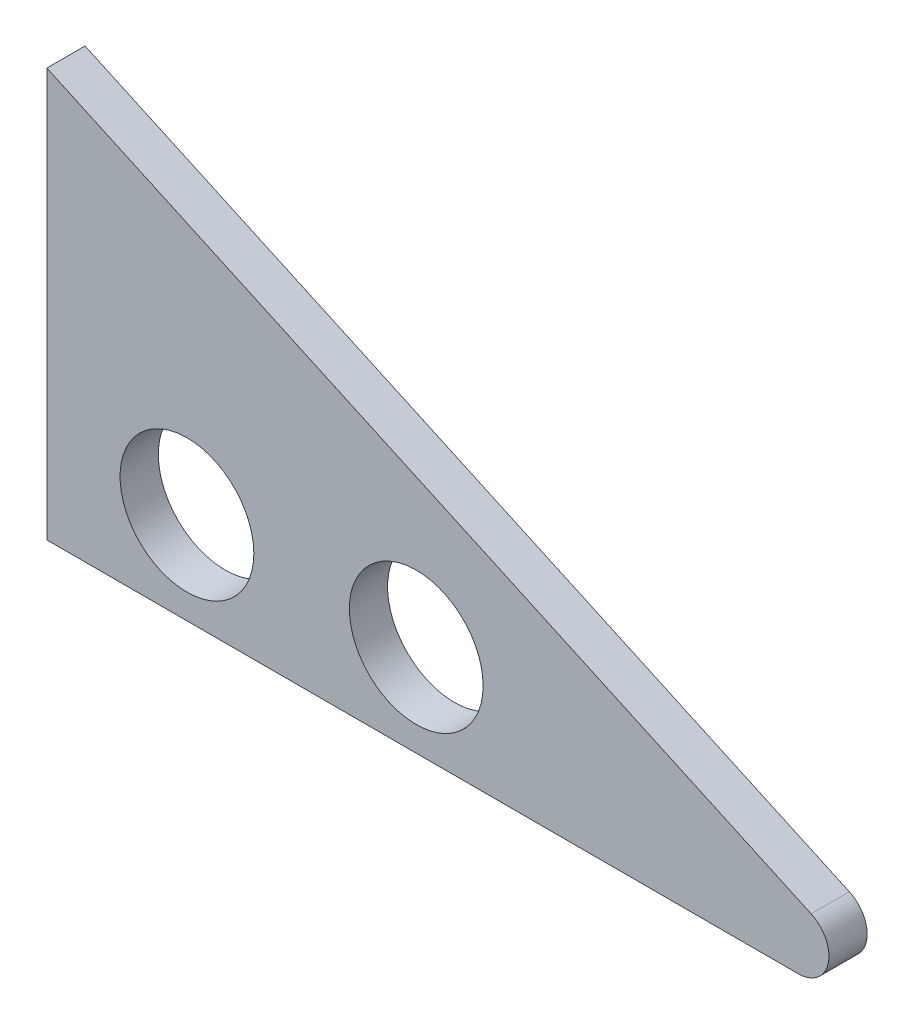
from build123d import *

# Parameters (mm, degrees)
SKETCH1_R      = 5.55625
EXTRUDE1_DEPTH = 3.175


with BuildPart() as part:
    # Sketch1 → Extrude1 (new body)
    with BuildSketch(Plane.XY):
        with BuildLine():
            Line((90.184030844, 0), (152.625697511, 0))
            ThreePointArc((152.625697511, 0), (155.107278383, 1.998376171), (153.684030844, 4.849010731))
            Line((153.684030844, 4.849010731), (90.184030844, 33.954188012))
            Line((90.184030844, 33.954188012), (90.184030844, 0))
        make_face()
        with Locations((120.875697511, 7.62)):
            Circle(SKETCH1_R, mode=Mode.SUBTRACT)
        with Locations((101.825697511, 7.62)):
            Circle(SKETCH1_R, mode=Mode.SUBTRACT)
    extrude(amount=EXTRUDE1_DEPTH)


solid = part.part
